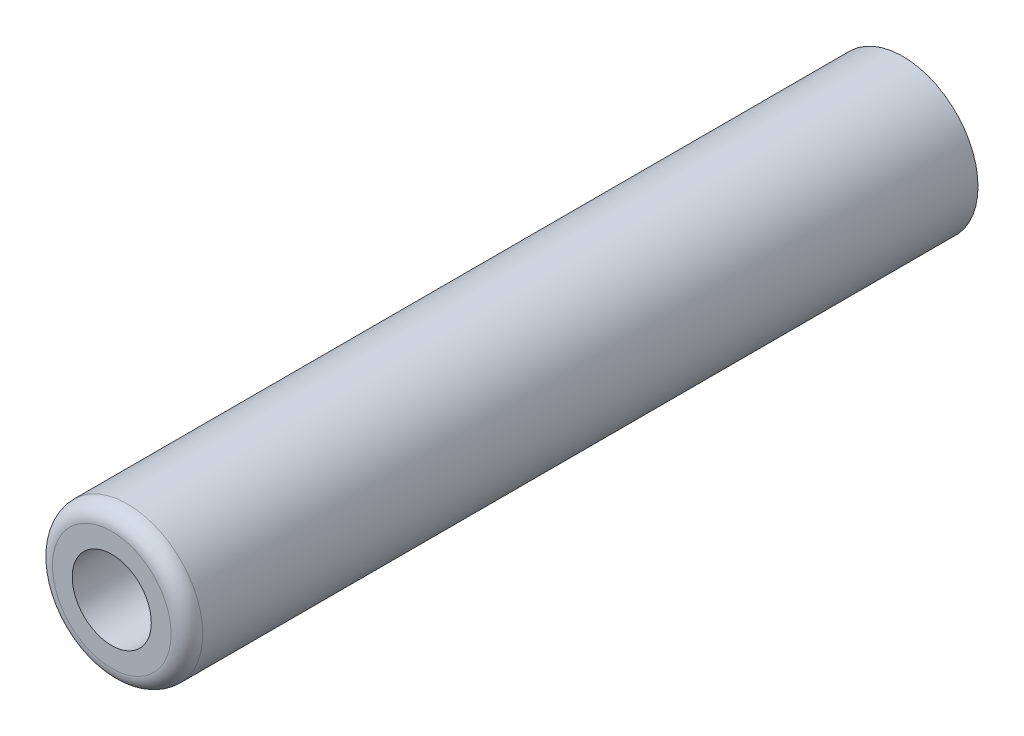
from build123d import *

# Parameters (mm, degrees)
SKETCH1_R               = 3.8
BOSS_EXTRUDE1_DEPTH     = 20
SKETCH2_R               = 2
CUT_EXTRUDE1_DEPTH      = 21
CUT_EXTRUDE1_DEPTH_BACK = 21
FILLET1_R               = 0.8


with BuildPart() as part:
    # Sketch1 → Boss-Extrude1 (new body, symmetric)
    with BuildSketch(Plane.XY):
        Circle(SKETCH1_R)
    extrude(amount=BOSS_EXTRUDE1_DEPTH, both=True)

    # Sketch2 → Cut-Extrude1 (cut, two sides)
    with BuildSketch(Plane.XY) as cut_extrude1_sk:
        Circle(SKETCH2_R)
    extrude(amount=CUT_EXTRUDE1_DEPTH, mode=Mode.SUBTRACT)
    extrude(cut_extrude1_sk.sketch, amount=-CUT_EXTRUDE1_DEPTH_BACK, mode=Mode.SUBTRACT)

    # Fillet1
    fillet1_edges = [part.edges().sort_by_distance(p)[0] for p in [
        (-3.8, 0, 20),
    ]]
    fillet(fillet1_edges, radius=FILLET1_R)


solid = part.part
